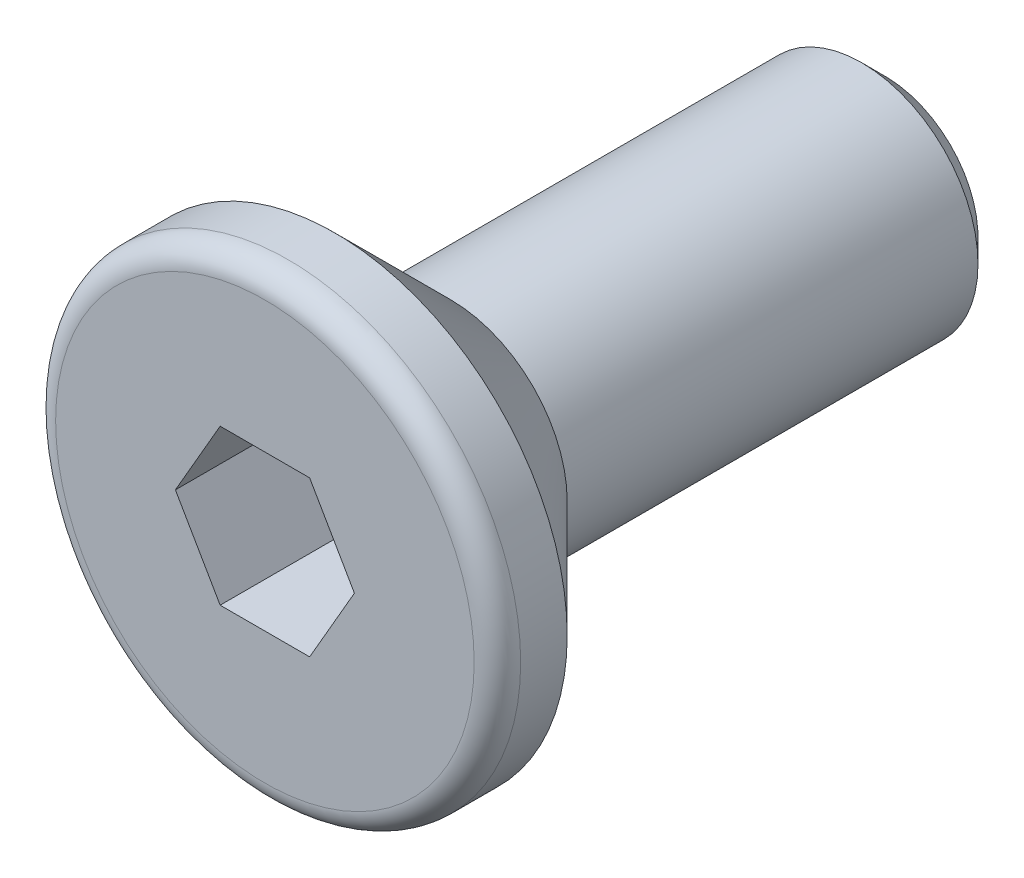
from build123d import *

# Parameters (mm, degrees)
CUT_EXTRUDE_1_DEPTH = 1.5
FILLET_1_R          = 0.3


with BuildPart() as part:
    # 草图1 → 旋转1 (revolve)
    with BuildSketch(Plane(origin=(0, 0, 0), x_dir=(0, 0, -1), z_dir=(1, 0, 0))):
        Polygon((-4, 0), (-4, 3), (-3.1, 3), (-1.6, 1.5), (3.7, 1.5), (4, 1.2), (4, 0), align=None)
    revolve(axis=Axis((0, 0, -4), (0, 0, 1)))

    # 草图2 → 切除-拉伸1 (cut)
    with BuildSketch(Plane.XY.offset(4)):
        Polygon((1.154700538, 0), (0.577350269, 1), (-0.577350269, 1), (-1.154700538, 0), (-0.577350269, -1), (0.577350269, -1), align=None)
    extrude(amount=-CUT_EXTRUDE_1_DEPTH, mode=Mode.SUBTRACT)

    # 圆角1
    fillet_1_edges = [part.edges().sort_by_distance(p)[0] for p in [
        (0, -3, 4),
    ]]
    fillet(fillet_1_edges, radius=FILLET_1_R)


solid = part.part
